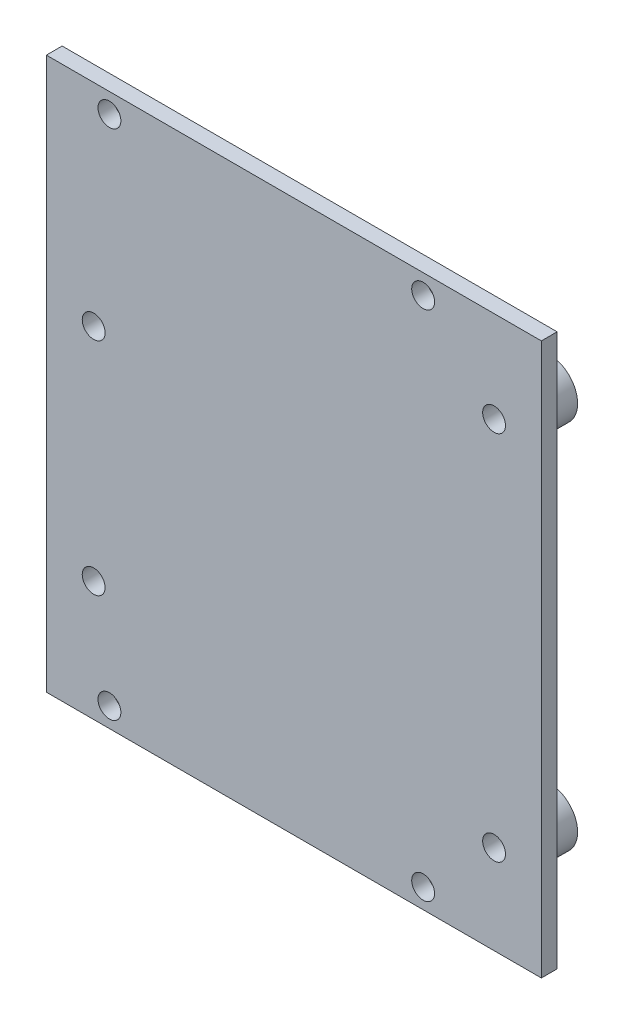
from build123d import *

# Parameters (mm, degrees)
SKETCH1_R                 = 3.6
SKETCH1_R_2               = 1.6
BOSS_EXTRUDE1_DEPTH       = 5
SKETCH2_W                 = 62.8
SKETCH2_H                 = 70
BOSS_EXTRUDE2_DEPTH       = 2
F_1_0MM_DOWEL_HOLE2_D     = 2.9
F_1_0MM_DOWEL_HOLE2_DEPTH = 9.128752102
F_1_0MM_DOWEL_HOLE2_TIP   = 0.871247898
F_1_0MM_DOWEL_HOLE3_D     = 2.9
F_1_0MM_DOWEL_HOLE3_DEPTH = 9.128752102
F_1_0MM_DOWEL_HOLE3_TIP   = 0.871247898


with BuildPart() as part:
    # Sketch1 → Boss-Extrude1 (new body)
    with BuildSketch(Plane.XY):
        with Locations((-33, -19.66)):
            Circle(SKETCH1_R)
        with Locations((-33, -19.66)):
            Circle(SKETCH1_R_2, mode=Mode.SUBTRACT)
        with Locations((-33, -19.66)):
            Circle(SKETCH1_R_2)
        with Locations((-33, 8.34)):
            Circle(SKETCH1_R)
        with Locations((17.8, -23.54)):
            Circle(SKETCH1_R)
        with Locations((17.8, 23.54)):
            Circle(SKETCH1_R)
    extrude(amount=BOSS_EXTRUDE1_DEPTH)

    # Sketch2 → Boss-Extrude2 (add)
    with BuildSketch(Plane.XY.offset(5)):
        with Locations((-7.6, 0.13)):
            Rectangle(SKETCH2_W, SKETCH2_H)
    extrude(amount=BOSS_EXTRUDE2_DEPTH)

    # Ø1.0mm Dowel Hole2
    with Locations(Plane(origin=(8.8, -32.37, 7), x_dir=(1, 0, 0), z_dir=(0, 0, 1))):
        with Locations((0, 0), (-39.8, 0), (-39.8, 65), (0, 65)):
            Hole(F_1_0MM_DOWEL_HOLE2_D / 2, depth=F_1_0MM_DOWEL_HOLE2_DEPTH)
            with Locations((0, 0, -(F_1_0MM_DOWEL_HOLE2_DEPTH + F_1_0MM_DOWEL_HOLE2_TIP / 2))):  # 118° drill point
                Cone(0, F_1_0MM_DOWEL_HOLE2_D / 2, F_1_0MM_DOWEL_HOLE2_TIP, mode=Mode.SUBTRACT)

    # Ø1.0mm Dowel Hole3
    with Locations(Plane(origin=(17.8, 23.54, 0), x_dir=(-1, 0, 0), z_dir=(0, 0, -1))):
        with Locations((0, 0), (50.8, -15.2), (50.8, -43.2), (0, -47.08)):
            Hole(F_1_0MM_DOWEL_HOLE3_D / 2, depth=F_1_0MM_DOWEL_HOLE3_DEPTH)
            with Locations((0, 0, -(F_1_0MM_DOWEL_HOLE3_DEPTH + F_1_0MM_DOWEL_HOLE3_TIP / 2))):  # 118° drill point
                Cone(0, F_1_0MM_DOWEL_HOLE3_D / 2, F_1_0MM_DOWEL_HOLE3_TIP, mode=Mode.SUBTRACT)


solid = part.part
